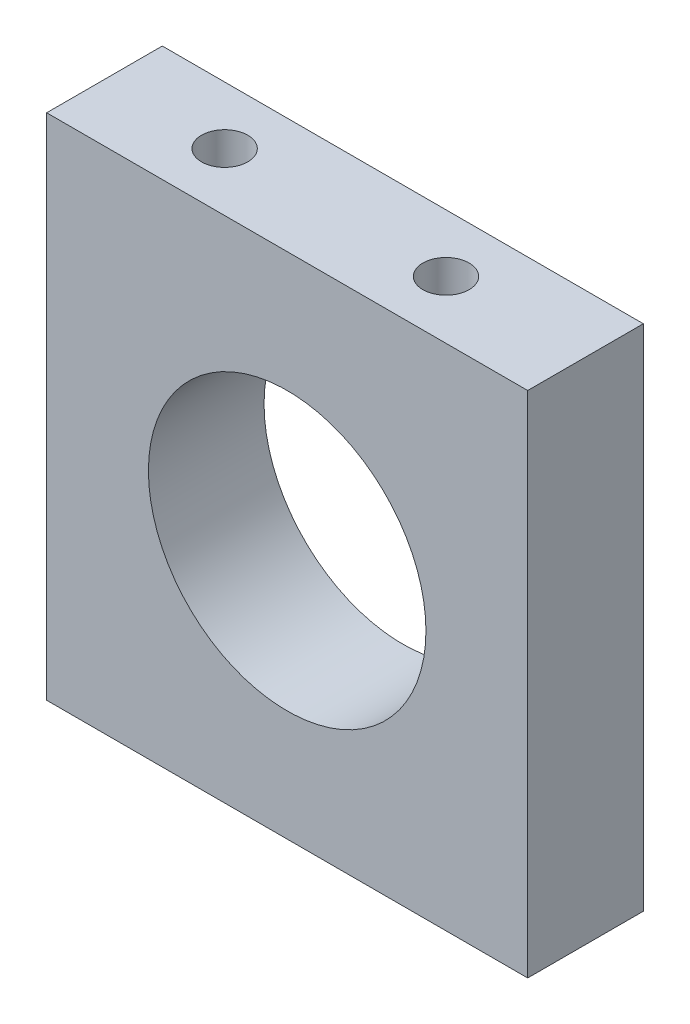
from build123d import *

# Parameters (mm, degrees)
SKETCH1_W                 = 52
SKETCH1_H                 = 55
BOSS_EXTRUDE1_DEPTH       = 12.5
SKETCH2_R                 = 15
CUT_EXTRUDE2_DEPTH        = 13.5
F_5_0MM_DOWEL_HOLE1_D     = 5
F_5_0MM_DOWEL_HOLE1_DEPTH = 10
F_5_0MM_DOWEL_HOLE1_TIP   = 1.502151548


with BuildPart() as part:
    # Sketch1 → Boss-Extrude1 (new body)
    with BuildSketch(Plane.XY):
        with Locations((0, 27.5)):
            Rectangle(SKETCH1_W, SKETCH1_H)
    extrude(amount=BOSS_EXTRUDE1_DEPTH)

    # Sketch2 → Cut-Extrude2 (cut, through all)
    with BuildSketch(Plane.XY.offset(12.5)):
        with Locations((0, 27)):
            Circle(SKETCH2_R)
    extrude(amount=-CUT_EXTRUDE2_DEPTH, mode=Mode.SUBTRACT)

    # Ø5.0mm Dowel Hole1
    with Locations(Plane(origin=(0, 55, 0), x_dir=(1, 0, 0), z_dir=(0, 1, 0))):
        with Locations((-13.030851483, -6.229198753), (10.897813178, -6.229198753)):
            Hole(F_5_0MM_DOWEL_HOLE1_D / 2, depth=F_5_0MM_DOWEL_HOLE1_DEPTH)
            with Locations((0, 0, -(F_5_0MM_DOWEL_HOLE1_DEPTH + F_5_0MM_DOWEL_HOLE1_TIP / 2))):  # 118° drill point
                Cone(0, F_5_0MM_DOWEL_HOLE1_D / 2, F_5_0MM_DOWEL_HOLE1_TIP, mode=Mode.SUBTRACT)


solid = part.part
